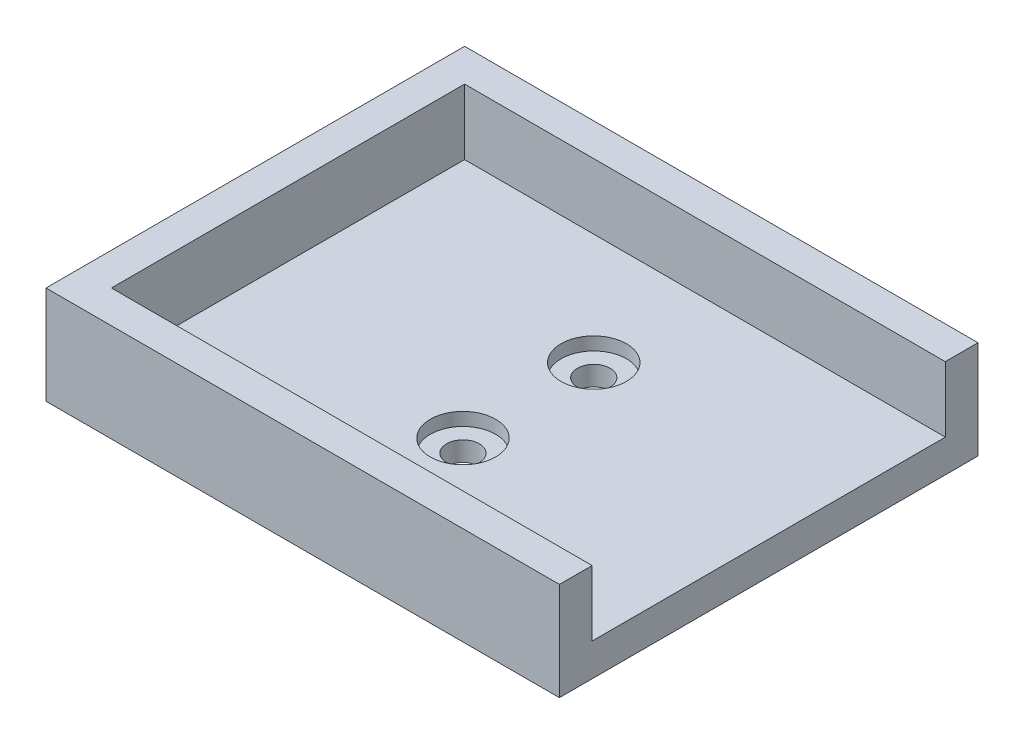
from build123d import *

# Parameters (mm, degrees)
SKETCH3_W               = 73.5
SKETCH3_H               = 54
BOSS_EXTRUDE2_DEPTH     = 5
BOSS_EXTRUDE4_DEPTH     = 15
SKETCH6_R               = 5
SKETCH6_R_2             = 2.5
CUT_EXTRUDE4_DEPTH      = 2
CUT_EXTRUDE5_DEPTH      = 10
CUT_EXTRUDE5_DEPTH_BACK = 55.699748628
SKETCH1_R               = 2.5
CUT_EXTRUDE6_START      = 10
SKETCH1_7_R             = 2.5
CUT_EXTRUDE6_DEPTH      = 10


with BuildPart() as part:
    # Sketch3 → Boss-Extrude2 (new body)
    with BuildSketch(Plane(origin=(0, 0, 0), x_dir=(1, 0, 0), z_dir=(0, 1, 0))):
        Rectangle(SKETCH3_W, SKETCH3_H)
    extrude(amount=BOSS_EXTRUDE2_DEPTH)

    # Sketch4 → Boss-Extrude4 (add)
    with BuildSketch(Plane(origin=(0, 0, 0), x_dir=(1, 0, 0), z_dir=(0, 1, 0))):
        Polygon((36.75, 32), (-41.75, 32), (-41.75, -32), (36.75, -32), (36.75, -27), (-36.75, -27), (-36.75, 27), (36.75, 27), align=None)
    extrude(amount=BOSS_EXTRUDE4_DEPTH)

    # Sketch6 → Cut-Extrude4 (cut)
    # profile 1 of 2: a face of its own
    with BuildSketch(Plane(origin=(0, 5, 0), x_dir=(1, 0, 0), z_dir=(0, 1, 0))):
        with Locations((0, 10)):
            Circle(SKETCH6_R)
        with Locations((0, 10)):
            Circle(SKETCH6_R_2, mode=Mode.SUBTRACT)
    # profile 2 of 2: a face of its own
    with BuildSketch(Plane(origin=(0, 5, 0), x_dir=(1, 0, 0), z_dir=(0, 1, 0))):
        with Locations((0, -10)):
            Circle(SKETCH6_R)
        with Locations((0, -10)):
            Circle(SKETCH6_R_2, mode=Mode.SUBTRACT)
    extrude(amount=-CUT_EXTRUDE4_DEPTH, mode=Mode.SUBTRACT)

    # Sketch1 → Cut-Extrude5 (cut, two sides: drawn at the far end of the back side and taken through both)
    with BuildSketch(Plane(origin=(0, 0, 0), x_dir=(1, 0, 0), z_dir=(0, 1, 0)).offset(-CUT_EXTRUDE5_DEPTH_BACK)):
        with Locations((0, 10)):
            Circle(SKETCH1_R)
    extrude(amount=CUT_EXTRUDE5_DEPTH + CUT_EXTRUDE5_DEPTH_BACK, mode=Mode.SUBTRACT)

    # Sketch1_7 → Cut-Extrude6 (cut)
    with BuildSketch(Plane(origin=(0, 0, 0), x_dir=(1, 0, 0), z_dir=(0, 1, 0)).offset(CUT_EXTRUDE6_START)):
        with Locations((0, -10)):
            Circle(SKETCH1_7_R)
    extrude(amount=-CUT_EXTRUDE6_DEPTH, mode=Mode.SUBTRACT)


solid = part.part
